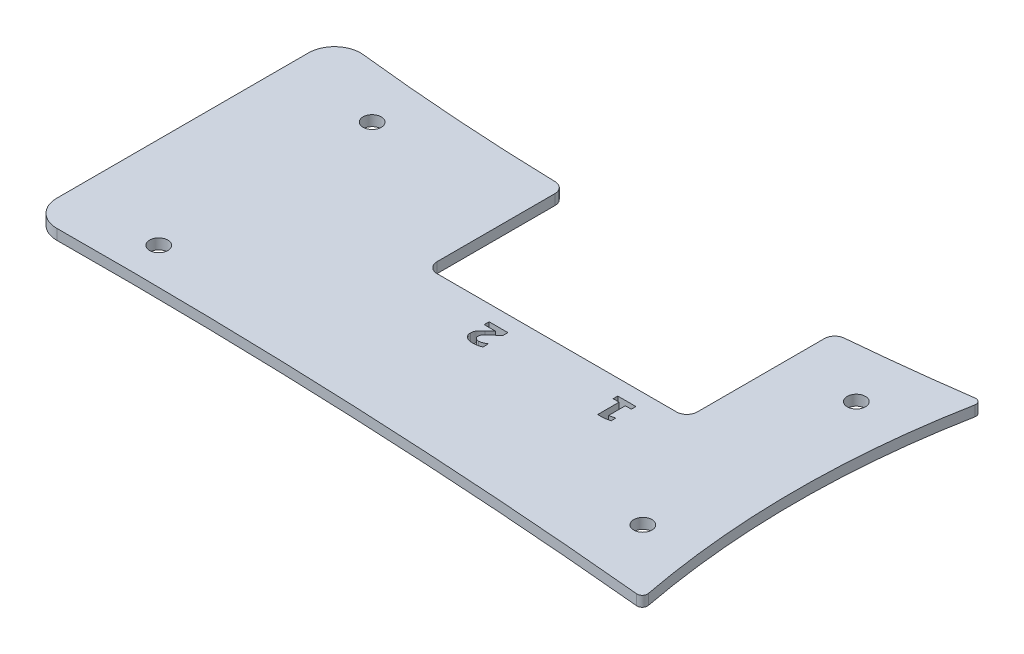
from build123d import *

# Parameters (mm, degrees)
CROQUIS1_R              = 2.175
SALIENTE_EXTRUIR1_DEPTH = 2
CROQUIS2_R              = 2.175
CROQUIS2_R_2            = 1.75
SALIENTE_EXTRUIR2_DEPTH = 2
CROQUIS3_W              = 50
CROQUIS3_H              = 30
CORTAR_EXTRUIR1_DEPTH   = 2
REDONDEO1_R             = 2
CORTAR_EXTRUIR2_DEPTH   = 2


with BuildPart() as part:
    # Croquis1 → Saliente-Extruir1 (new body)
    with BuildSketch(Plane(origin=(0, 0, 0), x_dir=(1, 0, 0), z_dir=(0, 1, 0))):
        with BuildLine():
            Line((-5.038018703, 53.362868047), (-5.038018703, 4.999855456))
            ThreePointArc((-5.038018703, 4.999855456), (-3.560085318, 1.450905363), (0, 0))
            ThreePointArc((0, 0), (58.295330849, -1.055734), (116.459334215, -5.106522257))
            ThreePointArc((116.459334215, -5.106522257), (117.294081225, -4.78404952), (117.536525368, -3.922648293))
            ThreePointArc((117.536525368, -3.922648293), (114.552978917, 27.433067341), (117.524427855, 58.789931717))
            ThreePointArc((117.524427855, 58.789931717), (117.266809662, 59.667185903), (116.403513339, 59.968286381))
            ThreePointArc((116.403513339, 59.968286381), (58.510820536, 55.521592761), (0.515666266, 58.332116778))
            ThreePointArc((0.515666266, 58.332116778), (-3.372053433, 57.089020542), (-5.038018703, 53.362868047))
        make_face()
        with Locations((105.593713907, 6.96520452)):
            Circle(CROQUIS1_R, mode=Mode.SUBTRACT)
        with Locations((105.593713907, 47.96520452)):
            Circle(CROQUIS1_R, mode=Mode.SUBTRACT)
        with Locations((12.593713907, 47.96520452)):
            Circle(CROQUIS1_R, mode=Mode.SUBTRACT)
        with Locations((12.593713907, 6.96520452)):
            Circle(CROQUIS1_R, mode=Mode.SUBTRACT)
    extrude(amount=SALIENTE_EXTRUIR1_DEPTH)

    # Croquis2 → Saliente-Extruir2 (add)
    with BuildSketch(Plane(origin=(0, 2, 0), x_dir=(1, 0, 0), z_dir=(0, 1, 0))):
        with Locations((12.593713907, 6.96520452)):
            Circle(CROQUIS2_R)
        with Locations((12.593713907, 6.96520452)):
            Circle(CROQUIS2_R_2, mode=Mode.SUBTRACT)
        with Locations((105.593713907, 6.96520452)):
            Circle(CROQUIS2_R)
        with Locations((105.593713907, 6.96520452)):
            Circle(CROQUIS2_R_2, mode=Mode.SUBTRACT)
        with Locations((105.593713907, 47.96520452)):
            Circle(CROQUIS2_R)
        with Locations((105.593713907, 47.96520452)):
            Circle(CROQUIS2_R_2, mode=Mode.SUBTRACT)
        with Locations((12.593713907, 47.96520452)):
            Circle(CROQUIS2_R)
        with Locations((12.593713907, 47.96520452)):
            Circle(CROQUIS2_R_2, mode=Mode.SUBTRACT)
    extrude(amount=-SALIENTE_EXTRUIR2_DEPTH)

    # Croquis3 → Cortar-Extruir1 (cut)
    with BuildSketch(Plane.XZ):
        with Locations((67.042264057, -43.977959042)):
            Rectangle(CROQUIS3_W, CROQUIS3_H)
    extrude(amount=-CORTAR_EXTRUIR1_DEPTH, mode=Mode.SUBTRACT)

    # Redondeo1
    redondeo1_edges = [part.edges().sort_by_distance(p)[0] for p in [
        (92.042264057, 1, -57.208472181),
        (42.042264057, 1, -55.581052497),
        (92.042264057, 1, -28.977959042),
        (42.042264057, 1, -28.977959042),
    ]]
    fillet(redondeo1_edges, radius=REDONDEO1_R)

    # Croquis5 → Cortar-Extruir2 (cut)
    with BuildSketch(Plane.XZ):
        Polygon((85.245219848, -25.091883093), (84.105979342, -25.091883093), (84.105979342, -21.864034991), (85.245219848, -22.117199548), (85.245219848, -21.231123599), (84.105979342, -20.977959042), (82.903447696, -20.977959042), (82.903447696, -25.091883093), (81.76420719, -25.091883093), (81.76420719, -25.977959042), (85.245219848, -25.977959042), align=None)
        with BuildLine():
            Line((59.23923156, -25.028591953), (57.043820167, -25.028591953))
            Line((57.043820167, -25.028591953), (57.043820167, -25.977959042))
            Line((57.043820167, -25.977959042), (60.651415104, -25.977959042))
            Line((60.651415104, -25.977959042), (60.651415104, -25.028591953))
            Line((60.651415104, -25.028591953), (58.849595484, -23.39686727))
            add(Edge.make_bspline(
                [(58.849595484, -23.39686727), (58.811179508, -23.360453729), (58.737347895, -23.290470593), (58.638846251, -23.181308349), (58.556039894, -23.073418427), (58.488647556, -22.9656663), (58.436579253, -22.857270202), (58.399356742, -22.7471273), (58.376788079, -22.635006299), (58.374215363, -22.559348688), (58.372934091, -22.521669485)],
                knots=[0, 0, 0, 0, 0.000158749, 0.0003051, 0.000440586, 0.000566273, 0.000685704, 0.000800474, 0.000914321, 0.001027271, 0.001027271, 0.001027271, 0.001027271], degree=3))
            add(Edge.make_bspline(
                [(58.372934091, -22.521669485), (58.373734222, -22.492954485), (58.375303557, -22.436634341), (58.386395262, -22.354534572), (58.403952327, -22.27651726), (58.429843029, -22.202852998), (58.463496065, -22.13358734), (58.504554072, -22.068788136), (58.55230711, -22.007870779), (58.607454048, -21.95191928), (58.668588665, -21.901761082), (58.734750953, -21.857510772), (58.805768742, -21.820347701), (58.881617778, -21.78880132), (58.962945343, -21.766978108), (59.048496141, -21.750115414), (59.138706913, -21.738517651), (59.200626269, -21.737813177), (59.232309091, -21.737452713)],
                knots=[0, 0, 0, 0, 8.6127e-05, 0.000168926, 0.000248089, 0.000325655, 0.000402613, 0.000478613, 0.000555374, 0.000634395, 0.000713787, 0.00079223, 0.000872741, 0.000953911, 0.001038132, 0.001124825, 0.001215473, 0.001310456, 0.001310456, 0.001310456, 0.001310456], degree=3))
            add(Edge.make_bspline(
                [(59.232309091, -21.737452713), (59.283483298, -21.739078861), (59.388654688, -21.742420863), (59.549919694, -21.767428422), (59.717848281, -21.808754845), (59.893140764, -21.864093074), (60.074545452, -21.936143809), (60.262356788, -22.023375721), (60.45625408, -22.126411077), (60.585178282, -22.203946693), (60.651415104, -22.243781827)],
                knots=[0, 0, 0, 0, 0.000153487, 0.000315441, 0.000488379, 0.00067197, 0.000866447, 0.001073517, 0.001292942, 0.001524792, 0.001524792, 0.001524792, 0.001524792], degree=3))
            Line((60.651415104, -22.243781827), (60.651415104, -21.16783246))
            add(Edge.make_bspline(
                [(60.651415104, -21.16783246), (60.580024738, -21.143346845), (60.438298447, -21.094737271), (60.22526093, -21.029932245), (60.012697372, -20.977227076), (59.802522423, -20.931042179), (59.593297587, -20.895451623), (59.386119489, -20.869557673), (59.180786794, -20.854336471), (59.044767338, -20.852359369), (58.977166686, -20.851376764)],
                knots=[0, 0, 0, 0, 0.000226414, 0.000449484, 0.000667747, 0.000883244, 0.001094922, 0.001304182, 0.001509426, 0.001712216, 0.001712216, 0.001712216, 0.001712216], degree=3))
            add(Edge.make_bspline(
                [(58.977166686, -20.851376764), (58.905262711, -20.85238657), (58.765150213, -20.854354283), (58.561236326, -20.873331522), (58.369861257, -20.904710686), (58.190983935, -20.948290574), (58.02362641, -21.003040105), (57.869196403, -21.072605629), (57.726828905, -21.153727261), (57.597883717, -21.246919107), (57.482225307, -21.350888685), (57.382280492, -21.4662574), (57.296169552, -21.590505745), (57.226253234, -21.725372616), (57.173379692, -21.870513757), (57.134463349, -22.024856787), (57.111652808, -22.189040836), (57.108650287, -22.301727129), (57.107111307, -22.359485941)],
                knots=[0, 0, 0, 0, 0.000215667, 0.00042025, 0.000613718, 0.000796966, 0.000972092, 0.001141183, 0.0013042, 0.001462847, 0.001617578, 0.001769683, 0.001919729, 0.002070114, 0.002224056, 0.002382117, 0.002546867, 0.00272011, 0.00272011, 0.00272011, 0.00272011], degree=3))
            add(Edge.make_bspline(
                [(57.107111307, -22.359485941), (57.109580941, -22.426905794), (57.114488685, -22.560884856), (57.153988801, -22.758138197), (57.220643738, -22.947717445), (57.29612885, -23.101195245), (57.373494642, -23.224613477), (57.44767263, -23.324133234), (57.534574057, -23.431842783), (57.636091495, -23.546775274), (57.751967056, -23.669028973), (57.881725831, -23.799417167), (58.024876774, -23.938220802), (58.127076255, -24.031061987), (58.180093902, -24.079224865)],
                knots=[0, 0, 0, 0, 0.00020215, 0.000401719, 0.000600628, 0.000803627, 0.00091338, 0.001037201, 0.001175739, 0.001328495, 0.001497091, 0.001681002, 0.001880326, 0.002095195, 0.002095195, 0.002095195, 0.002095195], degree=3))
            Line((58.180093902, -24.079224865), (59.23923156, -25.028591953))
        make_face()
    extrude(amount=-CORTAR_EXTRUIR2_DEPTH, mode=Mode.SUBTRACT)


solid = part.part
